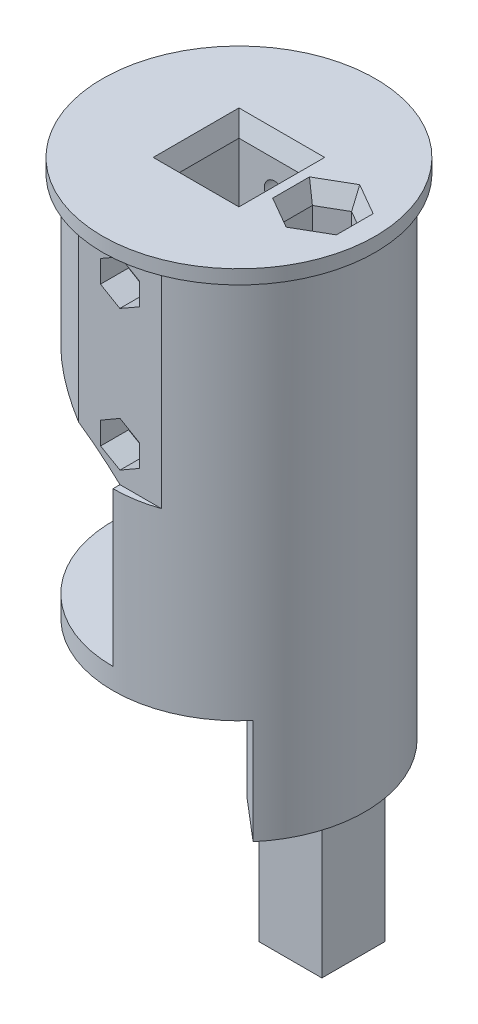
from build123d import *
from build123d.topology import SkipClean

# Parameters (mm, degrees)
SKETCH_1_R          = 18
EXTRUDE_1_DEPTH     = 55
SKETCH_2_R          = 19.5
EXTRUDE_2_DEPTH     = 2
SKETCH_3_W          = 10.25
SKETCH_3_H          = 10.25
CUT_EXTRUDE_1_DEPTH = 40
EXTRUDE_3_DEPTH     = 15
SKETCH1_R           = 18
BOSS_EXTRUDE1_DEPTH = 20
SKETCH3_R           = 18
BOSS_EXTRUDE2_DEPTH = 7
SKETCH4_W           = 10.2
SKETCH4_H           = 10.2
CUT_EXTRUDE2_DEPTH  = 27
CUT_EXTRUDE4_DEPTH  = 25
BOSS_EXTRUDE3_DEPTH = 3
SKETCH9_W           = 36
SKETCH9_H           = 22
CUT_EXTRUDE5_DEPTH  = 8
SKETCH10_R          = 3.7
SKETCH10_W          = 3
SKETCH10_H          = 2
CUT_EXTRUDE6_DEPTH  = 10
SKETCH11_R          = 2
CUT_EXTRUDE7_DEPTH  = 102
SKETCH15_R          = 18
CUT_EXTRUDE9_DEPTH  = 27
CUT_EXTRUDE11_DEPTH = 30
SKETCH18_R          = 1.5
CUT_EXTRUDE12_DEPTH = 71.437916
SKETCH19_R          = 3
CUT_EXTRUDE13_DEPTH = 3
BOSS_EXTRUDE5_DEPTH = 22
CUT_EXTRUDE16_DEPTH = 4
CUT_EXTRUDE17_DEPTH = 25.4
CUT_EXTRUDE18_DEPTH = 71.437916
FILLET2_R           = 5
SKETCH30_W          = 18.8
SKETCH30_H          = 10
CUT_EXTRUDE20_DEPTH = 3
CHAMFER1_SIZE       = 1
CHAMFER1_SIZE2      = 2.747477
CHAMFER2_SIZE       = 1
CHAMFER2_SIZE2      = 2.747477
SKETCH37_W          = 9
SKETCH37_H          = 9
SKETCH37_R          = 2
BOSS_EXTRUDE7_DEPTH = 20
CUT_EXTRUDE22_DEPTH = 15
CUT_EXTRUDE23_REACH = 79.101
SKETCH40_W          = 4.363156
SKETCH40_H          = 4.363157
CUT_EXTRUDE24_DEPTH = 10
FILLET7_R           = 6


with BuildPart() as part:
    # Эскиз1 → Бобышка-Вытянуть1 (new body)
    with BuildSketch(Plane(origin=(0, 0, 0), x_dir=(1, 0, 0), z_dir=(0, 1, 0))):
        with Locations(Location((0, 0, 0), (0, 0, 270))):
            Circle(SKETCH_1_R)
    extrude(amount=EXTRUDE_1_DEPTH)

    # Эскиз2 → Бобышка-Вытянуть2 (add)
    with BuildSketch(Plane(origin=(0, 55, 0), x_dir=(1, 0, 0), z_dir=(0, 1, 0))):
        with Locations(Location((0, 0, 0), (0, 0, 270))):
            Circle(SKETCH_2_R)
    extrude(amount=EXTRUDE_2_DEPTH)

    # Эскиз3 → Вырез-Вытянуть1 (cut)
    with BuildSketch(Plane(origin=(0, 57, 0), x_dir=(1, 0, 0), z_dir=(0, 1, 0))):
        Rectangle(SKETCH_3_W, SKETCH_3_H)
    extrude(amount=-CUT_EXTRUDE_1_DEPTH, mode=Mode.SUBTRACT)

    # Эскиз4 → Бобышка-Вытянуть3 (add)
    with BuildSketch(Plane.XZ):
        with BuildLine():
            Line((5.142301, -6.128356), (11.570177, -13.7888))
            ThreePointArc((11.570177, -13.7888), (17.937391, -1.5), (13.69962, 11.675633))
            Line((13.69962, 11.675633), (5.142301, 4.382576))
            Line((5.142301, 4.382576), (5.142301, -6.128356))
        make_face()
    extrude(amount=EXTRUDE_3_DEPTH)

    # Sketch1 → Boss-Extrude1 (add)
    with BuildSketch(Plane.XZ.offset(15)):
        with Locations(Location((0, 0, 0), (0, 0, 270))):
            Circle(SKETCH1_R)
    extrude(amount=BOSS_EXTRUDE1_DEPTH)

    # Sketch3 → Boss-Extrude2 (add)
    with BuildSketch(Plane.XZ.offset(35)):
        with Locations(Location((0, 0, 0), (0, 0, 270))):
            Circle(SKETCH3_R)
    extrude(amount=BOSS_EXTRUDE2_DEPTH)

    # Sketch4 → Cut-Extrude2 (cut)
    with BuildSketch(Plane.XZ.offset(42)):
        Rectangle(SKETCH4_W, SKETCH4_H)
    extrude(amount=-CUT_EXTRUDE2_DEPTH, mode=Mode.SUBTRACT)

    # Sketch6 → Cut-Extrude4 (cut)
    with BuildSketch(Plane.XZ):
        with BuildLine():
            Line((0, 18), (0, -18))
            ThreePointArc((0, -18), (-18, 0), (0, 18))
        make_face()
    extrude(amount=-CUT_EXTRUDE4_DEPTH, mode=Mode.SUBTRACT)

    # Sketch8 → Boss-Extrude3 (add)
    with BuildSketch(Plane.XZ):
        with BuildLine():
            Line((0, -18), (0, 18))
            ThreePointArc((0, 18), (-18, 0), (0, -18))
        make_face()
    extrude(amount=-BOSS_EXTRUDE3_DEPTH)

    # Sketch9 → Cut-Extrude5 (cut)
    with BuildSketch(Plane.ZY):
        with Locations((0, 14)):
            Rectangle(SKETCH9_W, SKETCH9_H)
    extrude(amount=-CUT_EXTRUDE5_DEPTH, mode=Mode.SUBTRACT)

    # Sketch10 → Cut-Extrude6 (cut)
    with BuildSketch(Plane.XZ):
        with Locations(Location((0, 0, 0), (0, 0, 270))):
            Circle(SKETCH10_R)
        with Locations((0, 7.7)):
            Rectangle(SKETCH10_W, SKETCH10_H)
    extrude(amount=-CUT_EXTRUDE6_DEPTH, mode=Mode.SUBTRACT)

    # Sketch11 → Cut-Extrude7 (cut)
    with BuildSketch(Plane.XZ.offset(42)):
        with Locations(Location((12, 0, 0), (0, 0, 270))):
            Circle(SKETCH11_R)
    extrude(amount=-CUT_EXTRUDE7_DEPTH, mode=Mode.SUBTRACT)

    # Sketch15 → Cut-Extrude9 (cut)
    with BuildSketch(Plane.XZ.offset(42)):
        with Locations(Location((0, 0, 0), (0, 0, 310))):
            Circle(SKETCH15_R)
    extrude(amount=-CUT_EXTRUDE9_DEPTH, mode=Mode.SUBTRACT)

    # Sketch17 → Cut-Extrude11 (cut)
    with BuildSketch(Plane.XZ.offset(-25)):
        with BuildLine():
            Line((5.91608, -17), (-5.91608, -17))
            ThreePointArc((-5.91608, -17), (0, -18), (5.91608, -17))
        make_face()
        with BuildLine():
            Line((5.91608, 17), (-5.91608, 17))
            ThreePointArc((-5.91608, 17), (0, 18), (5.91608, 17))
        make_face()
    extrude(amount=-CUT_EXTRUDE11_DEPTH, mode=Mode.SUBTRACT)

    # Sketch18 → Cut-Extrude12 (cut, through all)
    with BuildSketch(Plane.XY.offset(-17)):
        with Locations(Location((0, 30, 0), (0, 0, 180))):
            Circle(SKETCH18_R)
        with Locations(Location((0, 50, 0), (0, 0, 180))):
            Circle(SKETCH18_R)
    extrude(amount=CUT_EXTRUDE12_DEPTH, mode=Mode.SUBTRACT)

    # Sketch19 → Cut-Extrude13 (cut)
    with BuildSketch(Plane.XY.offset(-17)):
        with Locations((0, 30)):
            Circle(SKETCH19_R)
        with Locations((0, 50)):
            Circle(SKETCH19_R)
    extrude(amount=CUT_EXTRUDE13_DEPTH, mode=Mode.SUBTRACT)

    # Sketch23 → Boss-Extrude5 (add)
    with BuildSketch(Plane(origin=(0, 3, 0), x_dir=(1, 0, 0), z_dir=(0, 1, 0))):
        with BuildLine():
            Line((0, -14.4), (8, -14.4))
            Line((8, -14.4), (8, -16.124515))
            ThreePointArc((8, -16.124515), (4.10845, -17.524858), (0, -18))
            Line((0, -18), (0, -14.4))
        make_face()
        with BuildLine():
            Line((0, 14.4), (8, 14.4))
            Line((8, 14.4), (8, 16.124515))
            ThreePointArc((8, 16.124515), (4.10845, 17.524858), (0, 18))
            Line((0, 18), (0, 14.4))
        make_face()
    extrude(amount=BOSS_EXTRUDE5_DEPTH)

    # Sketch25 → Cut-Extrude16 (cut)
    with BuildSketch(Plane.XY.offset(17)):
        Polygon((2.771281, 28.4), (2.771281, 31.6), (0, 33.2), (-2.771281, 31.6), (-2.771281, 28.4), (0, 26.8), align=None)
        Polygon((-2.782127, 48.418934), (-0.02182, 46.800074), (2.760307, 48.38114), (2.782127, 51.581066), (0.02182, 53.199926), (-2.760307, 51.61886), align=None)
    extrude(amount=-CUT_EXTRUDE16_DEPTH, mode=Mode.SUBTRACT)

    # Sketch26 → Cut-Extrude17 (cut)
    with BuildSketch(Plane(origin=(0, 57, 0), x_dir=(1, 0, 0), z_dir=(0, 1, 0))):
        Polygon((8.449296, -2.05), (12, -4.1), (15.550704, -2.05), (15.550704, 2.05), (12, 4.1), (8.449296, 2.05), align=None)
    extrude(amount=-CUT_EXTRUDE17_DEPTH, mode=Mode.SUBTRACT)

    # Sketch27 → Cut-Extrude18 (cut, through all)
    with BuildSketch(Plane.XY.offset(17)):
        with BuildLine():
            Line((-20, 36.547005), (-20, 25))
            Line((-20, 25), (0, 25))
            ThreePointArc((0, 25), (-9.324199, 31.944024), (-20, 36.547005))
        make_face()
    extrude(amount=-CUT_EXTRUDE18_DEPTH, mode=Mode.SUBTRACT)

    # Fillet2
    fillet2_edges = [part.edges().sort_by_distance(p)[0] for p in [
        (8, 14, -14.4),
        (8, 14, 14.4),
    ]]
    fillet(fillet2_edges, radius=FILLET2_R)

    # Sketch30 → Cut-Extrude20 (cut)
    with BuildSketch(Plane.ZY.offset(-8)):
        with Locations((0, 8)):
            Rectangle(SKETCH30_W, SKETCH30_H)
    extrude(amount=-CUT_EXTRUDE20_DEPTH, mode=Mode.SUBTRACT)

    # Chamfer1
    chamfer1_edges = [part.edges().sort_by_distance(p)[0] for p in [
        (5.125, 57, 0),
        (0, 57, -5.125),
        (-5.125, 57, 0),
        (0, 57, 5.125),
    ]]
    chamfer1_side = [part.faces().sort_by_distance(p)[0] for p in [
        (0, 57, -18.948457),
    ]]
    chamfer(chamfer1_edges, length=CHAMFER1_SIZE, length2=CHAMFER1_SIZE2, reference=chamfer1_side[0])

    # Chamfer2
    chamfer2_edges = [part.edges().sort_by_distance(p)[0] for p in [
        (8.449296, 57, 0),
        (10.224648, 57, 3.075),
        (13.775352, 57, 3.075),
        (15.550704, 57, 0),
        (13.775352, 57, -3.075),
        (10.224648, 57, -3.075),
    ]]
    chamfer2_side = [part.faces().sort_by_distance(p)[0] for p in [
        (6.676543, 57, 0),
    ]]
    chamfer(chamfer2_edges, length=CHAMFER2_SIZE, length2=CHAMFER2_SIZE2, reference=chamfer2_side[0])

    # Sketch37 → Boss-Extrude7 (add)
    with SkipClean():  # the faces are left unmerged after this step: merging them gives an invalid solid
        with BuildSketch(Plane.XZ.offset(15)):
            with Locations((10.978823, -0.87289)):
                Rectangle(SKETCH37_W, SKETCH37_H)
            with Locations(Location((12, 0, 0), (0, 0, 270))):
                Circle(SKETCH37_R, mode=Mode.SUBTRACT)
        extrude(amount=BOSS_EXTRUDE7_DEPTH)

    # Sketch38 → Cut-Extrude22 (cut)
    with SkipClean():  # the faces are left unmerged after this step: merging them gives an invalid solid
        with BuildSketch(Plane.XZ.offset(15)):
            with BuildLine():
                Line((5.142301, -6.128356), (5.142301, 4.382576))
                ThreePointArc((5.142301, 4.382576), (5.978823, -0.87289), (5.142301, -6.128356))
            make_face()
        extrude(amount=-CUT_EXTRUDE22_DEPTH, mode=Mode.SUBTRACT)

    # Cut-Extrude23: up to this face of the body (flat: up to its plane)
    cut_extrude23_end = Plane(part.part.faces().sort_by_distance((9.45036, 13, 0))[0])
    # Sketch39 → Cut-Extrude23 (cut, up to the picked face)
    with BuildSketch(Plane.XZ.offset(15), mode=Mode.PRIVATE) as cut_extrude23_sk1:
        with BuildLine():
            Line((7.420734, -7.37289), (15.420734, -7.37289))
            ThreePointArc((15.420734, -7.37289), (13.728515, -10.030416), (11.598853, -12.352179))
            Line((11.598853, -12.352179), (7.420734, -7.37289))
        make_face()
    cut_extrude23_tool1 = split(extrude(cut_extrude23_sk1.sketch, amount=-CUT_EXTRUDE23_REACH, mode=Mode.PRIVATE), bisect_by=cut_extrude23_end, keep=Keep.BOTH, mode=Mode.PRIVATE)
    add(cut_extrude23_tool1.solids().sort_by(Axis((11.596211, -15, -9.081847), (0, 1, 0)))[0], mode=Mode.SUBTRACT)

    # Sketch40 → Cut-Extrude24 (cut)
    with SkipClean():  # the faces are left unmerged after this step: merging them gives an invalid solid
        with BuildSketch(Plane(origin=(0, 3, 0), x_dir=(1, 0, 0), z_dir=(0, 1, 0))):
            with Locations((9.602312, 9.554468)):
                Rectangle(SKETCH40_W, SKETCH40_H)
        extrude(amount=CUT_EXTRUDE24_DEPTH, mode=Mode.SUBTRACT)

    # Fillet7
    fillet7_edges = [part.edges().sort_by_distance(p)[0] for p in [
        (5.142301, -7.5, 4.382576),
        (5.142301, -7.5, -6.128356),
    ]]
    fillet(fillet7_edges, radius=FILLET7_R)


solid = part.part
